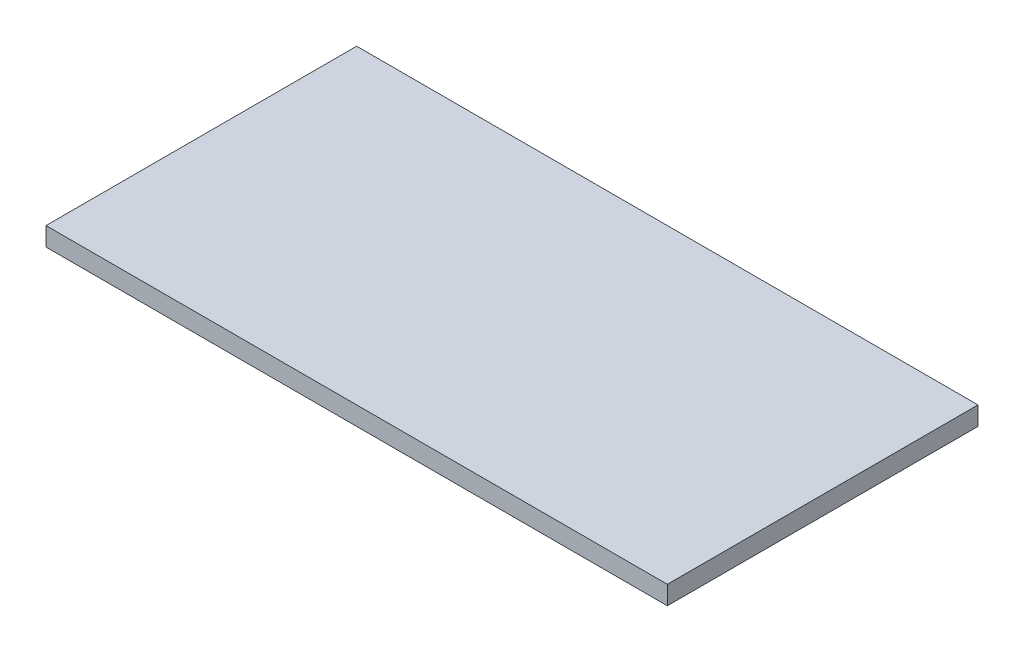
from build123d import *

# Parameters (mm, degrees)
SKETCH1_W           = 25.4
SKETCH1_H           = 12.7
BOSS_EXTRUDE1_DEPTH = 0.762


with BuildPart() as part:
    # Sketch1 → Boss-Extrude1 (new body)
    with BuildSketch(Plane(origin=(0, 0, 0), x_dir=(1, 0, 0), z_dir=(0, 1, 0))):
        Rectangle(SKETCH1_W, SKETCH1_H)
    extrude(amount=BOSS_EXTRUDE1_DEPTH)


solid = part.part
